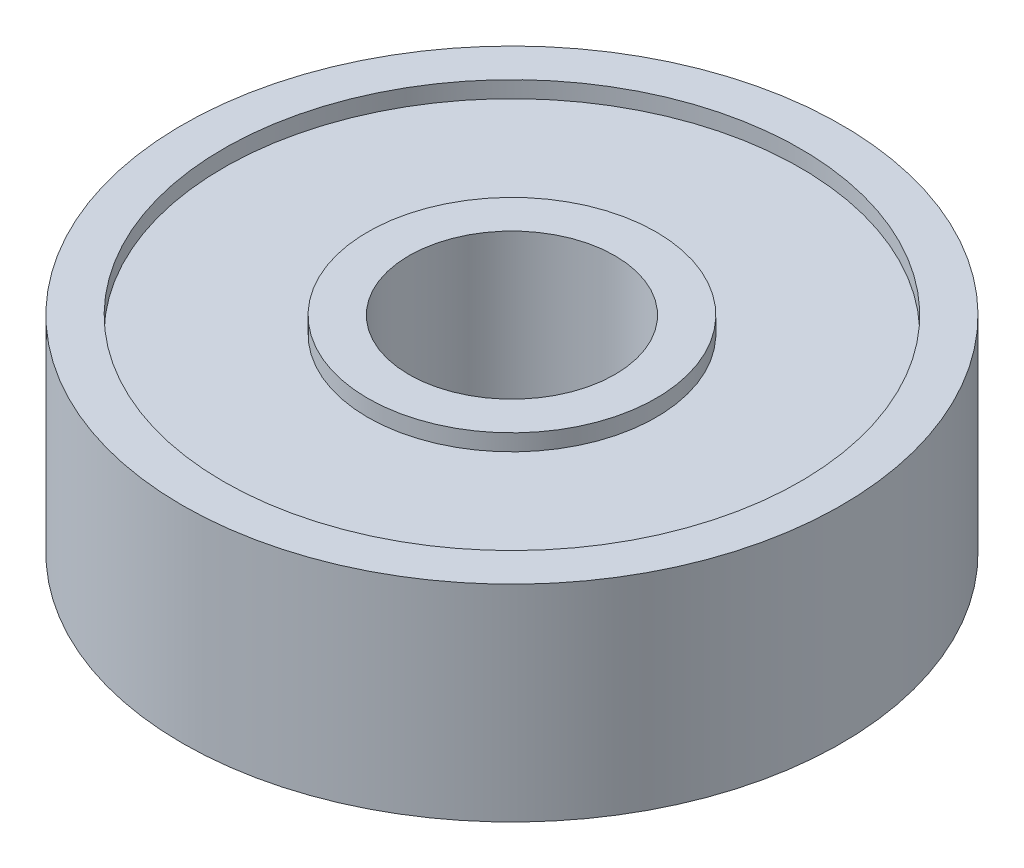
from build123d import *

# Parameters (mm, degrees)
BOSS_EXTRUDE1_DEPTH      = 2.5
BOSS_EXTRUDE1_DEPTH_BACK = 2.5
SKETCH1_R                = 8
SKETCH2_R                = 2.5
CUT_EXTRUDE1_DEPTH       = 13.369316877
SKETCH3_R                = 7
SKETCH3_R_2              = 3.5
CUT_EXTRUDE2_DEPTH       = 0.4


with BuildPart() as part:
    # Sketch1 → Boss-Extrude1 (new, two sides: drawn at the far end of the back side and taken through both)
    with BuildSketch(Plane(origin=(0, 0, 0), x_dir=(1, 0, 0), z_dir=(0, 1, 0)).offset(-BOSS_EXTRUDE1_DEPTH_BACK)):
        Circle(SKETCH1_R)
    extrude(amount=BOSS_EXTRUDE1_DEPTH + BOSS_EXTRUDE1_DEPTH_BACK)

    # Sketch2 → Cut-Extrude1 (cut, through all)
    with BuildSketch(Plane(origin=(0, 2.5, 0), x_dir=(1, 0, 0), z_dir=(0, 1, 0))):
        Circle(SKETCH2_R)
    extrude(amount=-CUT_EXTRUDE1_DEPTH, mode=Mode.SUBTRACT)

    # Sketch3 → Cut-Extrude2 (cut)
    with BuildSketch(Plane(origin=(0, 2.5, 0), x_dir=(1, 0, 0), z_dir=(0, 1, 0))):
        Circle(SKETCH3_R)
        Circle(SKETCH3_R_2, mode=Mode.SUBTRACT)
    cut_extrude2 = extrude(amount=-CUT_EXTRUDE2_DEPTH, mode=Mode.SUBTRACT)

    # Mirror1: Cut-Extrude2 across plane
    add(cut_extrude2.mirror(Plane.ZX), mode=Mode.SUBTRACT)


solid = part.part
